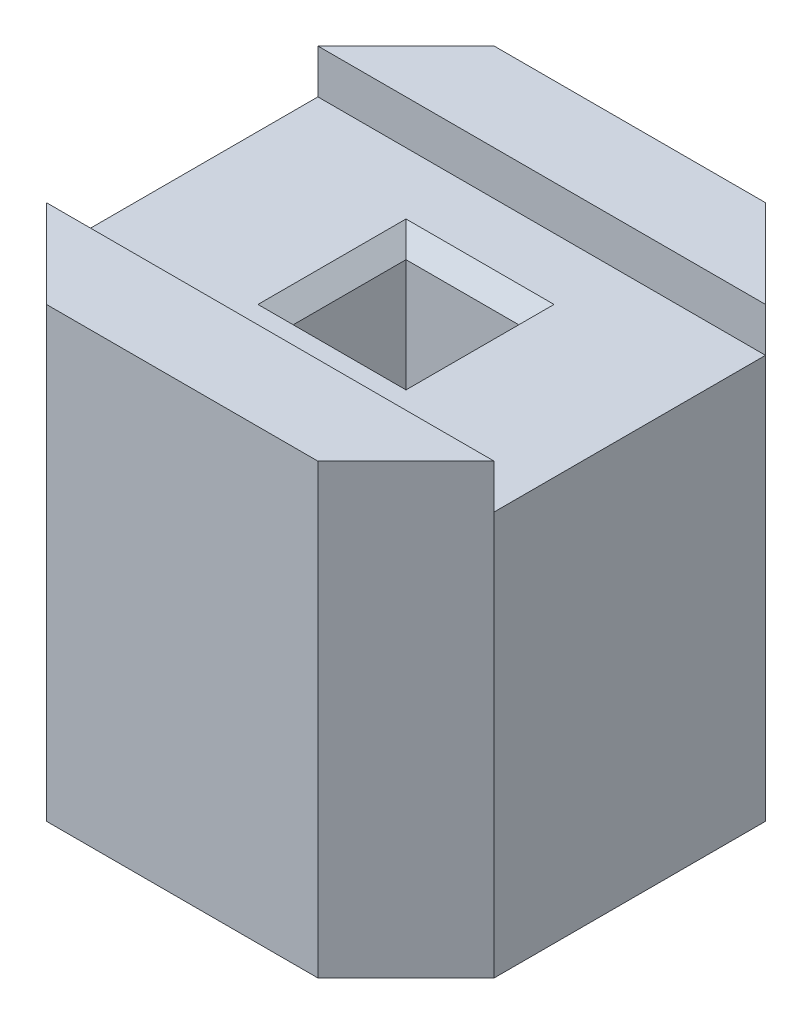
from build123d import *

# Parameters (mm, degrees)
SKETCH1_W           = 2.54
SKETCH1_H           = 2.54
BOSS_EXTRUDE1_DEPTH = 2.54
CHAMFER1_SIZE       = 0.5
SKETCH2_W           = 2.54
SKETCH2_H           = 1.54
CUT_EXTRUDE6_DEPTH  = 0.25
SKETCH3_W           = 0.64
SKETCH3_H           = 0.64
CUT_EXTRUDE7_DEPTH  = 3
CHAMFER4_SIZE       = 0.1


with BuildPart() as part:
    # Sketch1 → Boss-Extrude1 (new body)
    with BuildSketch(Plane.XY):
        with Locations((1.27, -1.27)):
            Rectangle(SKETCH1_W, SKETCH1_H)
    extrude(amount=BOSS_EXTRUDE1_DEPTH)

    # Chamfer1
    chamfer1_edges = [part.edges().sort_by_distance(p)[0] for p in [
        (2.54, -1.27, 2.54),
        (0, -1.27, 2.54),
        (2.54, -1.27, 0),
        (0, -1.27, 0),
    ]]
    chamfer(chamfer1_edges, length=CHAMFER1_SIZE)

    # Sketch2 → Cut-Extrude6 (cut)
    with BuildSketch(Plane(origin=(0, 0, 0), x_dir=(1, 0, 0), z_dir=(0, 1, 0))):
        with Locations((1.27, -1.27)):
            Rectangle(SKETCH2_W, SKETCH2_H)
    extrude(amount=-CUT_EXTRUDE6_DEPTH, mode=Mode.SUBTRACT)

    # Sketch3 → Cut-Extrude7 (cut)
    with BuildSketch(Plane(origin=(0, -0.25, 0), x_dir=(1, 0, 0), z_dir=(0, 1, 0))):
        with Locations((1.27, -1.27)):
            Rectangle(SKETCH3_W, SKETCH3_H)
    extrude(amount=-CUT_EXTRUDE7_DEPTH, mode=Mode.SUBTRACT)

    # Chamfer4
    chamfer4_edges = [part.edges().sort_by_distance(p)[0] for p in [
        (1.59, -0.25, 1.27),
        (1.27, -0.25, 0.95),
        (0.95, -0.25, 1.27),
        (1.27, -0.25, 1.59),
    ]]
    chamfer(chamfer4_edges, length=CHAMFER4_SIZE)


solid = part.part
